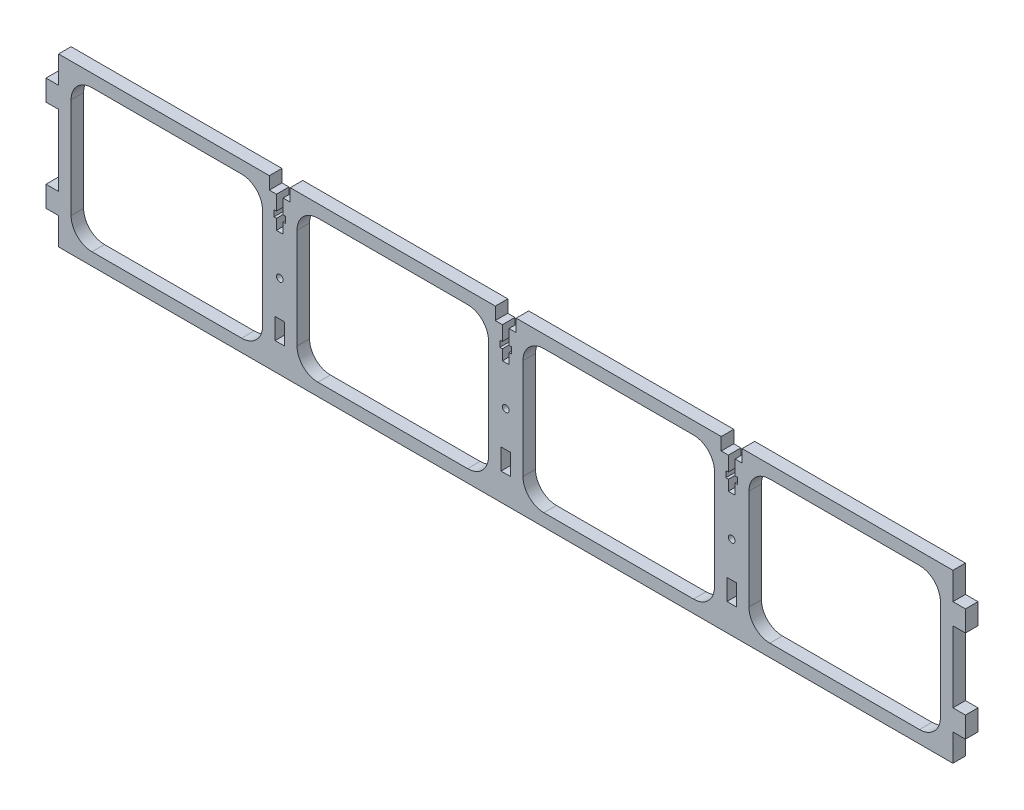
from build123d import *

# Parameters (mm, degrees)
SKETCH1_W           = 428
SKETCH1_H           = 80
BOSS_EXTRUDE1_DEPTH = 6
CUT_EXTRUDE1_DEPTH  = 6
LPATTERN1_COUNT     = 4
LPATTERN1_PITCH     = 108.125
SKETCH3_R           = 1.6
SKETCH3_W           = 4.5
SKETCH3_H           = 10
CUT_EXTRUDE2_DEPTH  = 7
SKETCH4_W           = 6
SKETCH4_H           = 10
BOSS_EXTRUDE2_DEPTH = 6
SKETCH5_W           = 10
SKETCH5_H           = 6
CUT_EXTRUDE3_DEPTH  = 6
CUT_EXTRUDE4_REACH  = 8


with BuildPart() as part:
    # Sketch1 → Boss-Extrude1 (new body)
    with BuildSketch(Plane.XY):
        Rectangle(SKETCH1_W, SKETCH1_H)
    extrude(amount=BOSS_EXTRUDE1_DEPTH)

    # Sketch2 → Cut-Extrude1 (cut)
    with BuildSketch(Plane.XY.offset(6)):
        with BuildLine():
            Line((-116.375, -24), (-116.375, 24))
            ThreePointArc((-116.375, 24), (-119.303932188, 31.071067812), (-126.375, 34))
            Line((-126.375, 34), (-198, 34))
            ThreePointArc((-198, 34), (-205.071067812, 31.071067812), (-208, 24))
            Line((-208, 24), (-208, -24))
            ThreePointArc((-208, -24), (-205.071067812, -31.071067812), (-198, -34))
            Line((-198, -34), (-126.375, -34))
            ThreePointArc((-126.375, -34), (-119.303932188, -31.071067812), (-116.375, -24))
        make_face()
    cut_extrude1 = extrude(amount=-CUT_EXTRUDE1_DEPTH, mode=Mode.SUBTRACT)

    # LPattern1: Cut-Extrude1 ×4
    with Locations(*[(i * LPATTERN1_PITCH, 0, 0) for i in range(1, LPATTERN1_COUNT)]):
        add(cut_extrude1, mode=Mode.SUBTRACT)

    # Sketch3 → Cut-Extrude2 (cut, through all)
    with BuildSketch(Plane(origin=(0, 0, 0), x_dir=(-1, 0, 0), z_dir=(0, 0, -1))):
        with Locations((108.125, 0)):
            Circle(SKETCH3_R)
        Circle(SKETCH3_R)
        with Locations((-108.125, 0)):
            Circle(SKETCH3_R)
        with Locations((-108.125, -22)):
            Rectangle(SKETCH3_W, SKETCH3_H)
        with Locations((0, -22)):
            Rectangle(SKETCH3_W, SKETCH3_H)
        with Locations((108.125, -22)):
            Rectangle(SKETCH3_W, SKETCH3_H)
    extrude(amount=-CUT_EXTRUDE2_DEPTH, mode=Mode.SUBTRACT)

    # Sketch4 → Boss-Extrude2 (add)
    with BuildSketch(Plane(origin=(0, 0, 0), x_dir=(-1, 0, 0), z_dir=(0, 0, -1))):
        with Locations((-217, 22)):
            Rectangle(SKETCH4_W, SKETCH4_H)
        with Locations((-217, -22)):
            Rectangle(SKETCH4_W, SKETCH4_H)
        with Locations((217, -22)):
            Rectangle(SKETCH4_W, SKETCH4_H)
        with Locations((217, 22)):
            Rectangle(SKETCH4_W, SKETCH4_H)
    extrude(amount=-BOSS_EXTRUDE2_DEPTH)

    # Sketch5 → Cut-Extrude3 (cut)
    with BuildSketch(Plane(origin=(0, 40, 0), x_dir=(1, 0, 0), z_dir=(0, 1, 0))):
        with Locations((-108.125, -3)):
            Rectangle(SKETCH5_W, SKETCH5_H)
        with Locations((0, -3)):
            Rectangle(SKETCH5_W, SKETCH5_H)
        with Locations((108.125, -3)):
            Rectangle(SKETCH5_W, SKETCH5_H)
    extrude(amount=-CUT_EXTRUDE3_DEPTH, mode=Mode.SUBTRACT)

    # Sketch6 → Cut-Extrude4 (cut, up to next)
    with BuildSketch(Plane(origin=(0, 0, 0), x_dir=(-1, 0, 0), z_dir=(0, 0, -1)), mode=Mode.PRIVATE) as cut_extrude4_sk1:
        Polygon((-109.725, 34), (-109.725, 27), (-110.925, 27), (-110.925, 24), (-109.725, 24), (-109.725, 19), (-106.525, 19), (-106.525, 24), (-105.325, 24), (-105.325, 27), (-106.525, 27), (-106.525, 34), align=None)
    cut_extrude4_tool1 = extrude(cut_extrude4_sk1.sketch, amount=-CUT_EXTRUDE4_REACH, mode=Mode.PRIVATE) & part.part
    add(cut_extrude4_tool1.solids().sort_by_distance((108.125, 26.369565, 0))[0], mode=Mode.SUBTRACT)
    # Sketch6 → Cut-Extrude4 (cut, up to next)
    with BuildSketch(Plane(origin=(0, 0, 0), x_dir=(-1, 0, 0), z_dir=(0, 0, -1)), mode=Mode.PRIVATE) as cut_extrude4_sk2:
        Polygon((-1.595, 27), (-2.795, 27), (-2.795, 24), (-1.595, 24), (-1.595, 19), (1.605, 19), (1.605, 24), (2.805, 24), (2.805, 27), (1.605, 27), (1.605, 34), (-1.595, 34), align=None)
    cut_extrude4_tool2 = extrude(cut_extrude4_sk2.sketch, amount=-CUT_EXTRUDE4_REACH, mode=Mode.PRIVATE) & part.part
    add(cut_extrude4_tool2.solids().sort_by_distance((-0.005, 26.369565, 0))[0], mode=Mode.SUBTRACT)
    # Sketch6 → Cut-Extrude4 (cut, up to next)
    with BuildSketch(Plane(origin=(0, 0, 0), x_dir=(-1, 0, 0), z_dir=(0, 0, -1)), mode=Mode.PRIVATE) as cut_extrude4_sk3:
        Polygon((106.535, 34), (106.535, 27), (105.335, 27), (105.335, 24), (106.535, 24), (106.535, 19), (109.735, 19), (109.735, 24), (110.935, 24), (110.935, 27), (109.735, 27), (109.735, 34), align=None)
    cut_extrude4_tool3 = extrude(cut_extrude4_sk3.sketch, amount=-CUT_EXTRUDE4_REACH, mode=Mode.PRIVATE) & part.part
    add(cut_extrude4_tool3.solids().sort_by_distance((-108.135, 26.369565, 0))[0], mode=Mode.SUBTRACT)


solid = part.part
